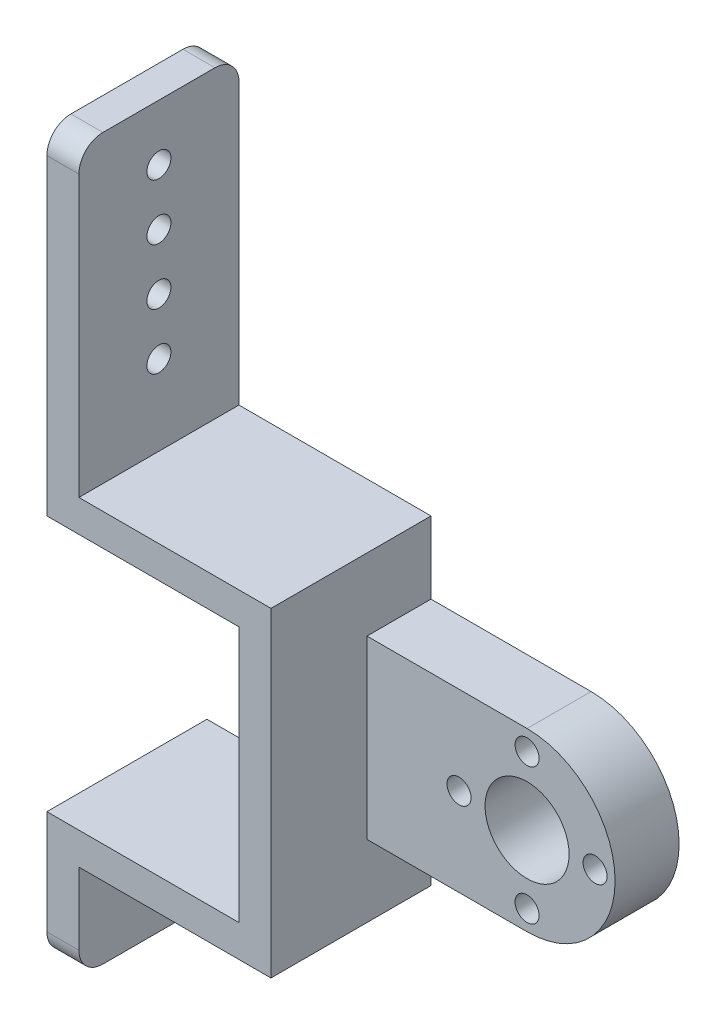
from build123d import *

# Parameters (mm, degrees)
BOSS_EXTRUDE2_DEPTH  = 8
SKETCH3_R            = 5.25
CUT_EXTRUDE1_DEPTH   = 8
SKETCH7_W            = 4
SKETCH7_H            = 9
BOSS_EXTRUDE3_DEPTH  = 8
SKETCH8_W            = 4
SKETCH8_H            = 40
BOSS_EXTRUDE4_DEPTH  = 12
SKETCH9_W            = 20
SKETCH9_H            = 4
BOSS_EXTRUDE5_DEPTH  = 24
SKETCH10_W           = 20
SKETCH10_H           = 4
BOSS_EXTRUDE6_DEPTH  = 24
SKETCH12_W           = 4
SKETCH12_H           = 38
BOSS_EXTRUDE7_DEPTH  = 20
SKETCH13_W           = 4
SKETCH13_H           = 20
BOSS_EXTRUDE8_DEPTH  = 12
SKETCH14_R           = 1.5
CUT_EXTRUDE2_DEPTH   = 12
SKETCH15_R           = 1.5
CUT_EXTRUDE3_DEPTH   = 12
FILLET1_R            = 3
SKETCH16_R           = 1.5
CUT_EXTRUDE4_DEPTH   = 12
SKETCH21_W           = 8
SKETCH21_H           = 22
BOSS_EXTRUDE9_DEPTH  = 20
SKETCH22_R           = 11
BOSS_EXTRUDE10_DEPTH = 8
SKETCH23_R           = 1.5
SKETCH23_R_2         = 5.25
CUT_EXTRUDE6_DEPTH   = 21
SKETCH24_R           = 1.5
SKETCH24_R_2         = 5.25
CUT_EXTRUDE7_DEPTH   = 8


with BuildPart() as part:
    # Sketch1 → Boss-Extrude2 (new body)
    with BuildSketch(Plane.XY):
        with BuildLine():
            ThreePointArc((12, 11), (1, 0), (12, -11))
            Line((12, -11), (12, 11))
        make_face()
        with BuildLine():
            Line((12, 11), (12, -11))
            ThreePointArc((12, -11), (19.778174593, -7.778174593), (23, 0))
            ThreePointArc((23, 0), (19.778174593, 7.778174593), (12, 11))
        make_face()
        with BuildLine():
            Line((-12, 11), (-12, -11))
            Line((-12, -11), (12, -11))
            ThreePointArc((12, -11), (1, 0), (12, 11))
            Line((12, 11), (-12, 11))
        make_face()
    extrude(amount=BOSS_EXTRUDE2_DEPTH)

    # Sketch3 → Cut-Extrude1 (cut)
    with BuildSketch(Plane.XY.offset(8)):
        with Locations((12, 0)):
            Circle(SKETCH3_R)
    extrude(amount=-CUT_EXTRUDE1_DEPTH, mode=Mode.SUBTRACT)

    # Sketch7 → Boss-Extrude3 (add)
    with BuildSketch(Plane.XY.offset(8)):
        with Locations((-10, 15.5)):
            Rectangle(SKETCH7_W, SKETCH7_H)
        with Locations((-10, -15.5)):
            Rectangle(SKETCH7_W, SKETCH7_H)
    extrude(amount=-BOSS_EXTRUDE3_DEPTH)

    # Sketch8 → Boss-Extrude4 (add)
    with BuildSketch(Plane(origin=(0, 0, 0), x_dir=(-1, 0, 0), z_dir=(0, 0, -1))):
        with Locations((10, 0)):
            Rectangle(SKETCH8_W, SKETCH8_H)
    extrude(amount=BOSS_EXTRUDE4_DEPTH)

    # Sketch9 → Boss-Extrude5 (add)
    with BuildSketch(Plane.ZY.offset(12)):
        with Locations((-2, 18)):
            Rectangle(SKETCH9_W, SKETCH9_H)
    extrude(amount=BOSS_EXTRUDE5_DEPTH)

    # Sketch10 → Boss-Extrude6 (add)
    with BuildSketch(Plane.ZY.offset(12)):
        with Locations((-2, -18)):
            Rectangle(SKETCH10_W, SKETCH10_H)
    extrude(amount=BOSS_EXTRUDE6_DEPTH)

    # Sketch12 → Boss-Extrude7 (add)
    with BuildSketch(Plane(origin=(0, 0, -12), x_dir=(-1, 0, 0), z_dir=(0, 0, -1))):
        with Locations((34, 39)):
            Rectangle(SKETCH12_W, SKETCH12_H)
    extrude(amount=-BOSS_EXTRUDE7_DEPTH)

    # Sketch13 → Boss-Extrude8 (add)
    with BuildSketch(Plane.XZ.offset(20)):
        with Locations((-34, -2)):
            Rectangle(SKETCH13_W, SKETCH13_H)
    extrude(amount=BOSS_EXTRUDE8_DEPTH)

    # Sketch14 → Cut-Extrude2 (cut)
    with BuildSketch(Plane.ZY.offset(36)):
        with Locations((-2, -27.5)):
            Circle(SKETCH14_R)
    extrude(amount=-CUT_EXTRUDE2_DEPTH, mode=Mode.SUBTRACT)

    # Sketch15 → Cut-Extrude3 (cut)
    with BuildSketch(Plane.ZY.offset(36)):
        with Locations((-2, 51)):
            Circle(SKETCH15_R)
        with Locations((-2, 44)):
            Circle(SKETCH15_R)
        with Locations((-2, 37)):
            Circle(SKETCH15_R)
        with Locations((-2, 30)):
            Circle(SKETCH15_R)
    extrude(amount=-CUT_EXTRUDE3_DEPTH, mode=Mode.SUBTRACT)

    # Fillet1
    fillet1_edges = [part.edges().sort_by_distance(p)[0] for p in [
        (-34, -32, -12),
        (-34, -32, 8),
        (-34, 58, 8),
        (-34, 58, -12),
    ]]
    fillet(fillet1_edges, radius=FILLET1_R)

    # Sketch16 → Cut-Extrude4 (cut)
    with BuildSketch(Plane(origin=(0, 0, 0), x_dir=(-1, 0, 0), z_dir=(0, 0, -1))):
        with Locations((-12, 8.5)):
            Circle(SKETCH16_R)
        with Locations((-20.5, 0)):
            Circle(SKETCH16_R)
        with Locations((-12, -8.5)):
            Circle(SKETCH16_R)
        with Locations((-3.5, 0)):
            Circle(SKETCH16_R)
    extrude(amount=-CUT_EXTRUDE4_DEPTH, mode=Mode.SUBTRACT)

    # Sketch21 → Boss-Extrude9 (add)
    with BuildSketch(Plane(origin=(-8, 0, 0), x_dir=(0, 0, -1), z_dir=(1, 0, 0))):
        with Locations((8, 0)):
            Rectangle(SKETCH21_W, SKETCH21_H)
    extrude(amount=BOSS_EXTRUDE9_DEPTH)

    # Sketch22 → Boss-Extrude10 (add)
    with BuildSketch(Plane(origin=(0, 0, -12), x_dir=(-1, 0, 0), z_dir=(0, 0, -1))):
        with Locations((-12, 0)):
            Circle(SKETCH22_R)
    extrude(amount=-BOSS_EXTRUDE10_DEPTH)

    # Sketch23 → Cut-Extrude6 (cut, through all)
    with BuildSketch(Plane.XY.offset(8)):
        with Locations((12, 8.5)):
            Circle(SKETCH23_R)
        with Locations((20.5, 0)):
            Circle(SKETCH23_R)
        with Locations((3.5, 0)):
            Circle(SKETCH23_R)
        with Locations((12, -8.5)):
            Circle(SKETCH23_R)
        with Locations((12, 0)):
            Circle(SKETCH23_R_2)
    extrude(amount=-CUT_EXTRUDE6_DEPTH, mode=Mode.SUBTRACT)

    # Sketch24 → Cut-Extrude7 (cut)
    with BuildSketch(Plane.XY.offset(8)):
        with BuildLine():
            Line((12, 11), (-8, 11))
            Line((-8, 11), (-8, -11))
            Line((-8, -11), (12, -11))
            ThreePointArc((12, -11), (1, 0), (12, 11))
        make_face()
        with BuildLine():
            Line((12, 10), (12, 11))
            ThreePointArc((12, 11), (1, 0), (12, -11))
            Line((12, -11), (12, -10))
            ThreePointArc((12, -10), (10.5, -8.5), (12, -7))
            Line((12, -7), (12, -5.25))
            ThreePointArc((12, -5.25), (6.75, 0), (12, 5.25))
            Line((12, 5.25), (12, 7))
            ThreePointArc((12, 7), (10.5, 8.5), (12, 10))
        make_face()
        with Locations((3.5, 0)):
            Circle(SKETCH24_R, mode=Mode.SUBTRACT)
        with Locations((12, 8.5)):
            Circle(SKETCH24_R)
        with Locations((12, 0)):
            Circle(SKETCH24_R_2)
        with Locations((12, -8.5)):
            Circle(SKETCH24_R)
        with BuildLine():
            Line((12, 11), (12, -11))
            ThreePointArc((12, -11), (23, 0), (12, 11))
        make_face()
        with Locations((20.5, 0)):
            Circle(SKETCH24_R, mode=Mode.SUBTRACT)
    extrude(amount=-CUT_EXTRUDE7_DEPTH, mode=Mode.SUBTRACT)


solid = part.part
